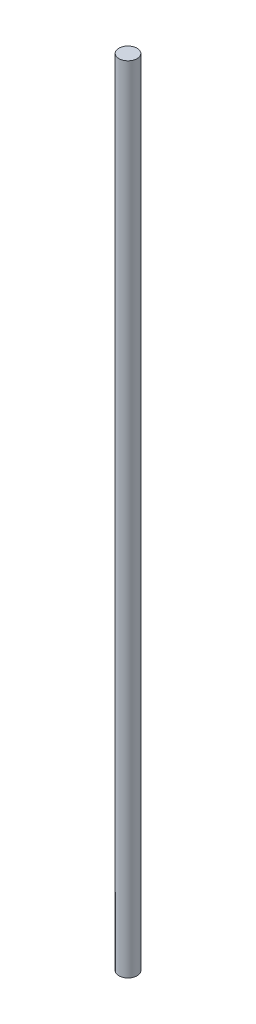
from build123d import *

# Parameters (mm, degrees)
SKETCH1_R           = 4
BOSS_EXTRUDE1_DEPTH = 350


with BuildPart() as part:
    # Sketch1 → Boss-Extrude1 (new body)
    with BuildSketch(Plane(origin=(0, 0, 0), x_dir=(1, 0, 0), z_dir=(0, 1, 0))):
        Circle(SKETCH1_R)
    extrude(amount=BOSS_EXTRUDE1_DEPTH)


solid = part.part
